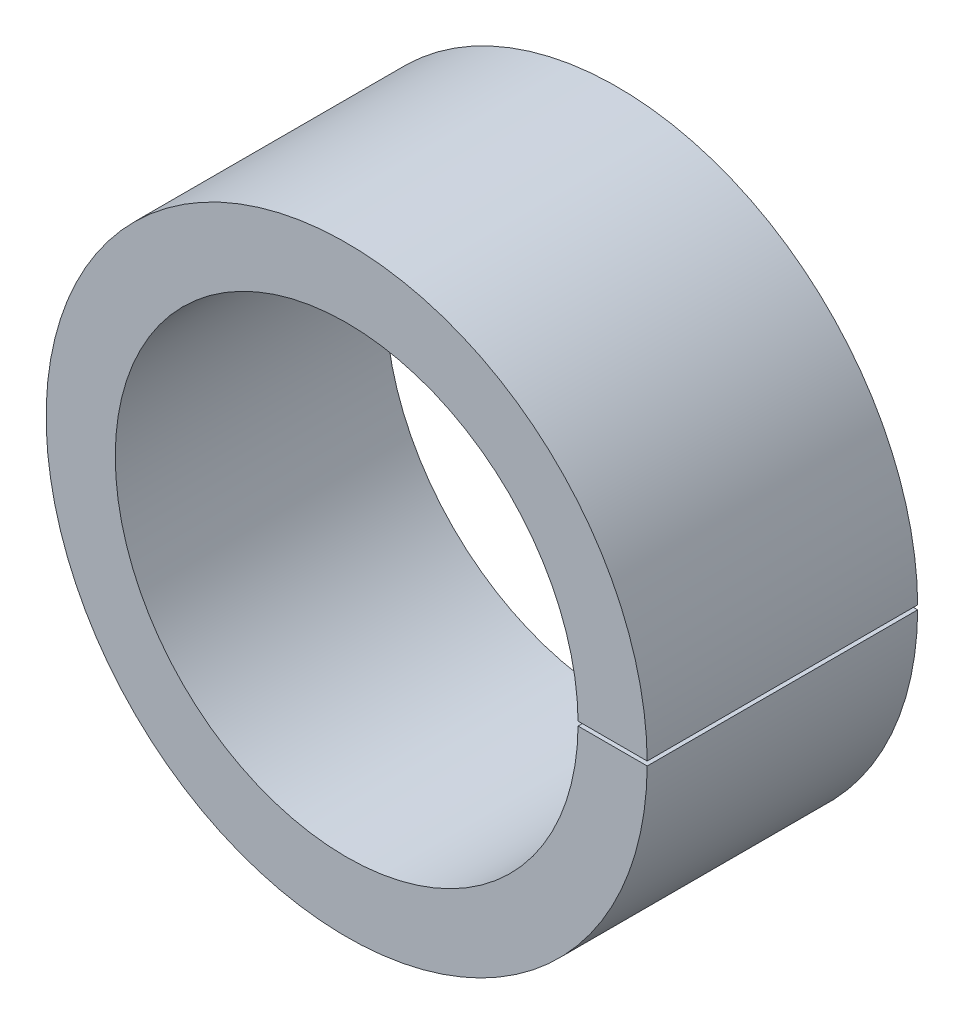
from build123d import *

# Parameters (mm, degrees)
BOSS_EXTRUDE1_DEPTH      = 4.7625
BOSS_EXTRUDE1_DEPTH_BACK = 4.7625
SKETCH4_W                = 24.044105213
SKETCH4_H                = 22.52166187
CUT_EXTRUDE1_DEPTH       = 3.81


with BuildPart() as part:
    # Sketch3 → Boss-Extrude1 (new body, two sides)
    with BuildSketch(Plane.XY) as boss_extrude1_sk:
        with BuildLine():
            Line((4.889292919, 0.045), (6.349840549, 0.045))
            ThreePointArc((6.349840549, 0.045), (-6.35, 0), (6.349840549, -0.045))
            Line((6.349840549, -0.045), (4.889292919, -0.045))
            ThreePointArc((4.889292919, -0.045), (-4.8895, 0), (4.889292919, 0.045))
        make_face()
    extrude(amount=BOSS_EXTRUDE1_DEPTH)
    extrude(boss_extrude1_sk.sketch, amount=-BOSS_EXTRUDE1_DEPTH_BACK)

    # Sketch4 → Cut-Extrude1 (cut)
    with BuildSketch(Plane(origin=(0, 0, -4.7625), x_dir=(-1, 0, 0), z_dir=(0, 0, -1))):
        with Locations((-0.7086439, 0.118120604)):
            Rectangle(SKETCH4_W, SKETCH4_H)
    extrude(amount=-CUT_EXTRUDE1_DEPTH, mode=Mode.SUBTRACT)


solid = part.part
